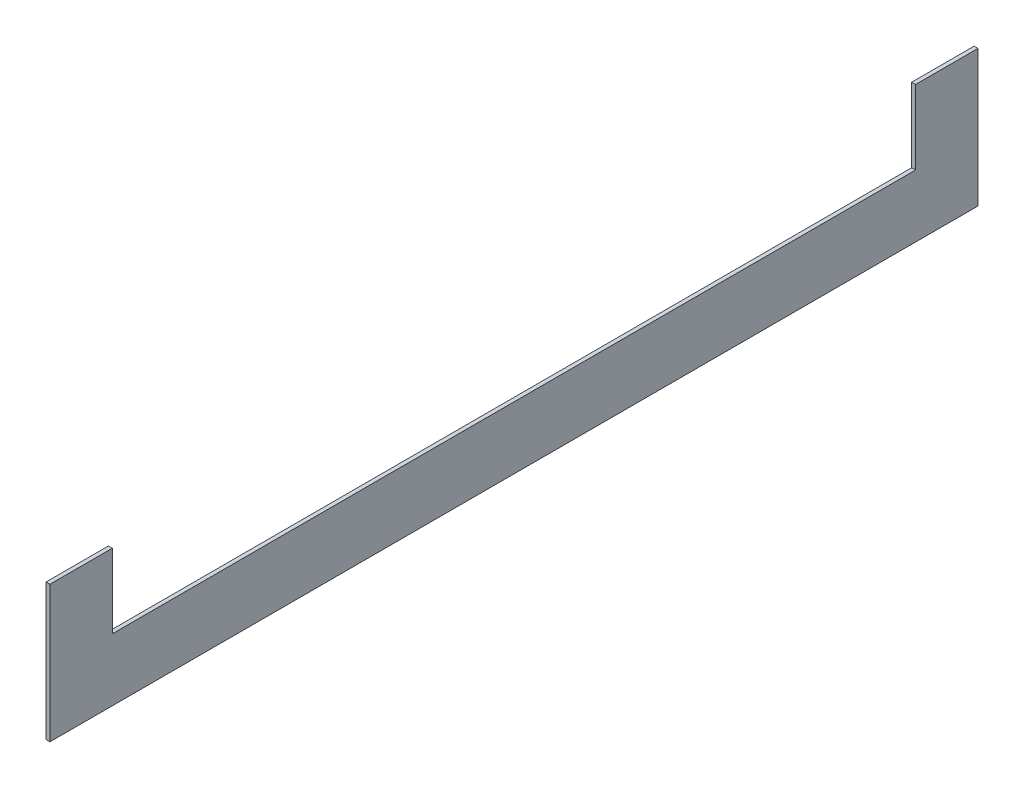
from build123d import *

# Parameters (mm, degrees)
BOSS_EXTRUDE1_DEPTH = 3.175


with BuildPart() as part:
    # Sketch1 → Boss-Extrude1 (new body)
    with BuildSketch(Plane(origin=(0, 0, 0), x_dir=(0, 0, -1), z_dir=(1, 0, 0))):
        Polygon((-377.825, 0), (377.825, 0), (377.825, 111.125), (327.025, 111.125), (327.025, 50.8), (-327.025, 50.8), (-327.025, 111.125), (-377.825, 111.125), align=None)
    extrude(amount=BOSS_EXTRUDE1_DEPTH)


solid = part.part
